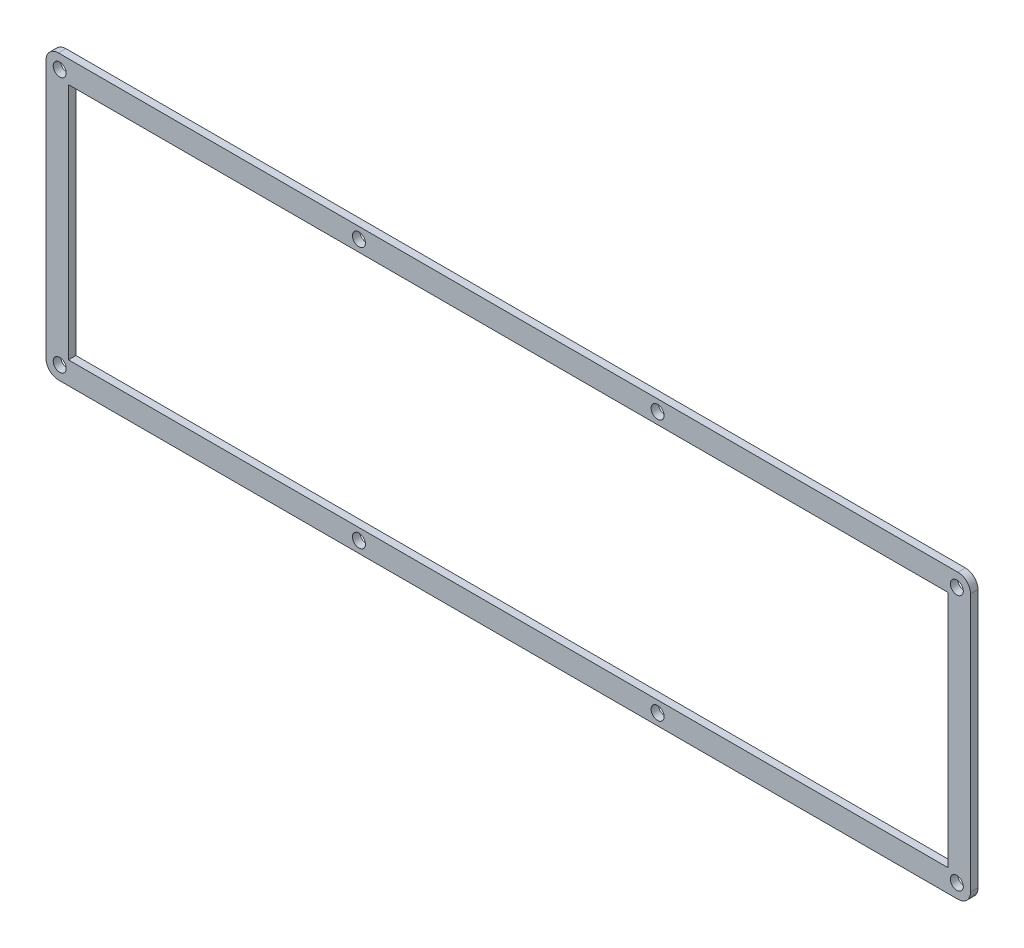
from build123d import *

# Parameters (mm, degrees)
MODEL_R             = 2.6
MODEL_W             = 352.775
MODEL_H             = 95.6
BOSS_EXTRUDE1_DEPTH = 3


with BuildPart() as part:
    # Model → Boss-Extrude1 (new body)
    with BuildSketch(Plane.XY):
        with BuildLine():
            Line((0, 108.6), (0, 5))
            ThreePointArc((0, 5), (1.464466094, 1.464466094), (5, 0))
            Line((5, 0), (365.775, 0))
            ThreePointArc((365.775, 0), (369.310533906, 1.464466094), (370.775, 5))
            Line((370.775, 5), (370.775, 108.6))
            ThreePointArc((370.775, 108.6), (369.310533906, 112.135533906), (365.775, 113.6))
            Line((365.775, 113.6), (5, 113.6))
            ThreePointArc((5, 113.6), (1.464466094, 112.135533906), (0, 108.6))
        make_face()
        with Locations((5.5, 108.1)):
            Circle(MODEL_R, mode=Mode.SUBTRACT)
        with Locations((5.5, 5.5)):
            Circle(MODEL_R, mode=Mode.SUBTRACT)
        with Locations((365.275, 5.5)):
            Circle(MODEL_R, mode=Mode.SUBTRACT)
        with Locations((365.275, 108.1)):
            Circle(MODEL_R, mode=Mode.SUBTRACT)
        with Locations((125.5, 4.5)):
            Circle(MODEL_R, mode=Mode.SUBTRACT)
        with Locations((245.275, 4.5)):
            Circle(MODEL_R, mode=Mode.SUBTRACT)
        with Locations((125.5, 109.1)):
            Circle(MODEL_R, mode=Mode.SUBTRACT)
        with Locations((245.275, 109.1)):
            Circle(MODEL_R, mode=Mode.SUBTRACT)
        with Locations((185.3875, 56.8)):
            Rectangle(MODEL_W, MODEL_H, mode=Mode.SUBTRACT)
    extrude(amount=BOSS_EXTRUDE1_DEPTH)


solid = part.part
